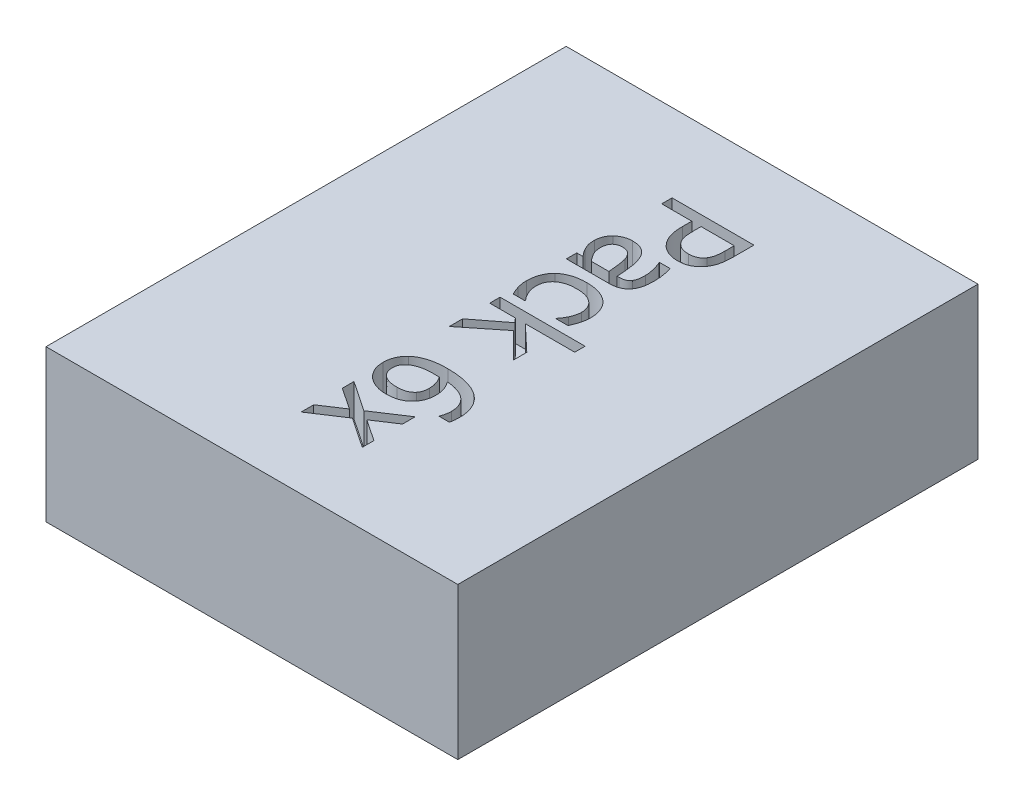
from build123d import *

# Parameters (mm, degrees)
SKETCH1_W           = 38
SKETCH1_H           = 14
BOSS_EXTRUDE1_DEPTH = 48
CUT_EXTRUDE1_DEPTH  = 3


with BuildPart() as part:
    # Sketch1 → Boss-Extrude1 (new body)
    with BuildSketch(Plane.XY):
        Rectangle(SKETCH1_W, SKETCH1_H)
    extrude(amount=BOSS_EXTRUDE1_DEPTH)

    # Sketch2 → Cut-Extrude1 (cut)
    with BuildSketch(Plane(origin=(0, 7, 0), x_dir=(1, 0, 0), z_dir=(0, 1, 0))):
        with BuildLine():
            add(Edge.make_bspline(
                [(3.247819021, -12.001203397), (3.166017395, -11.999505775), (3.003662304, -11.996136435), (2.764297073, -11.959652494), (2.531343241, -11.905343398), (2.307750042, -11.826775929), (2.094742675, -11.731458665), (1.898188136, -11.614545571), (1.715028941, -11.484211033), (1.607405271, -11.381596731), (1.553765815, -11.330453935)],
                knots=[0, 0, 0, 0, 0.000245218, 0.000486695, 0.000724751, 0.000961915, 0.001196573, 0.001423573, 0.00164708, 0.001869161, 0.001869161, 0.001869161, 0.001869161], degree=3))
            add(Edge.make_bspline(
                [(1.553765815, -11.330453935), (1.490690236, -11.263236352), (1.364664717, -11.128935074), (1.208368294, -10.900417457), (1.070026889, -10.658608827), (0.956698106, -10.395418802), (0.869496109, -10.104784869), (0.807935038, -9.782006196), (0.770776554, -9.42414577), (0.766980665, -9.173892861), (0.765000301, -9.04333272)],
                knots=[0, 0, 0, 0, 0.000276157, 0.000551763, 0.000828037, 0.00111109, 0.001409285, 0.001736539, 0.002095523, 0.0024871, 0.0024871, 0.0024871, 0.0024871], degree=3))
            Line((0.765000301, -9.04333272), (0.765000301, -8.176885755))
            Line((0.765000301, -8.176885755), (-2.007629989, -8.176885755))
            Line((-2.007629989, -8.176885755), (-2.007629989, -7.220806344))
            Line((-2.007629989, -7.220806344), (5.545397354, -7.220806344))
            Line((5.545397354, -7.220806344), (5.545397354, -9.122508047))
            add(Edge.make_bspline(
                [(5.545397354, -9.122508047), (5.543922544, -9.230596056), (5.541085497, -9.438521622), (5.520745917, -9.737857764), (5.484996583, -10.012211973), (5.436338134, -10.263551645), (5.371869763, -10.4957725), (5.28927761, -10.711729631), (5.190167504, -10.914523817), (5.108984036, -11.038908552), (5.068851523, -11.100397327)],
                knots=[0, 0, 0, 0, 0.000324257, 0.000623763, 0.000899483, 0.001153784, 0.001391202, 0.001621476, 0.001846621, 0.002066728, 0.002066728, 0.002066728, 0.002066728], degree=3))
            add(Edge.make_bspline(
                [(5.068851523, -11.100397327), (5.018725731, -11.168500818), (4.919494112, -11.303322021), (4.741782651, -11.480824552), (4.545099061, -11.634761619), (4.33037673, -11.768187733), (4.093134351, -11.87411868), (3.832096463, -11.94795925), (3.547686736, -11.993455227), (3.350079722, -11.998561121), (3.247819021, -12.001203397)],
                knots=[0, 0, 0, 0, 0.000253396, 0.000501635, 0.000750579, 0.001001412, 0.001258206, 0.001527224, 0.001813101, 0.002119709, 0.002119709, 0.002119709, 0.002119709], degree=3))
        make_face()
        with BuildLine():
            add(Edge.make_bspline(
                [(3.223917036, -10.949516045), (3.288234658, -10.947762396), (3.412914767, -10.944362936), (3.593401558, -10.91911716), (3.760270828, -10.875733826), (3.914536132, -10.815704042), (4.056140104, -10.738447022), (4.182183333, -10.640530147), (4.29865251, -10.528938843), (4.360661088, -10.440278397), (4.392126565, -10.395288762)],
                knots=[0, 0, 0, 0, 0.000192918, 0.000373973, 0.000545359, 0.000709032, 0.00086951, 0.001027268, 0.001186777, 0.001351103, 0.001351103, 0.001351103, 0.001351103], degree=3))
            add(Edge.make_bspline(
                [(4.392126565, -10.395288762), (4.418174298, -10.354073576), (4.471060507, -10.270392013), (4.529750909, -10.131861513), (4.582469222, -9.985767795), (4.620244151, -9.82673694), (4.650434169, -9.653165097), (4.670764223, -9.461036231), (4.682178311, -9.24962905), (4.683986018, -9.102106481), (4.684925885, -9.025406231)],
                knots=[0, 0, 0, 0, 0.000146033, 0.0002965, 0.00045005, 0.000611644, 0.000786018, 0.000978374, 0.001190841, 0.001420941, 0.001420941, 0.001420941, 0.001420941], degree=3))
            Line((4.684925885, -9.025406231), (4.684925885, -8.176885755))
            Line((4.684925885, -8.176885755), (1.625471771, -8.176885755))
            Line((1.625471771, -8.176885755), (1.625471771, -8.874524949))
            add(Edge.make_bspline(
                [(1.625471771, -8.874524949), (1.626346609, -8.973158383), (1.628009853, -9.160680306), (1.647617026, -9.427003126), (1.678102295, -9.663635985), (1.720536308, -9.873641097), (1.780087162, -10.060852664), (1.860877965, -10.229355242), (1.959716739, -10.382815713), (2.041895714, -10.471082164), (2.082597239, -10.514798688)],
                knots=[0, 0, 0, 0, 0.000295847, 0.000562465, 0.000800573, 0.00101123, 0.001204449, 0.001388202, 0.001570509, 0.001749407, 0.001749407, 0.001749407, 0.001749407], degree=3))
            add(Edge.make_bspline(
                [(2.082597239, -10.514798688), (2.121123908, -10.551129631), (2.196798579, -10.622491424), (2.322642342, -10.711343495), (2.450584854, -10.788752122), (2.585943778, -10.849641585), (2.730138763, -10.894186189), (2.88455006, -10.927137172), (3.05062549, -10.946611097), (3.165105632, -10.948530169), (3.223917036, -10.949516045)],
                knots=[0, 0, 0, 0, 0.000158674, 0.000311671, 0.000461036, 0.000606801, 0.000755628, 0.000912967, 0.001079921, 0.001256299, 0.001256299, 0.001256299, 0.001256299], degree=3))
        make_face(mode=Mode.SUBTRACT)
        with BuildLine():
            add(Edge.make_bspline(
                [(-1.441451713, -16.016736921), (-1.457424795, -15.995851723), (-1.491972199, -15.950680138), (-1.546770282, -15.877237547), (-1.611071154, -15.795090461), (-1.707533725, -15.677384419), (-1.819666444, -15.524797571), (-1.8923424, -15.393561549), (-1.926960789, -15.331048719)],
                knots=[0, 0, 0, 0, 7.8879e-05, 0.000170603, 0.000274897, 0.000391782, 0.000627265, 0.000841468, 0.000841468, 0.000841468, 0.000841468], degree=3))
            add(Edge.make_bspline(
                [(-1.926960789, -15.331048719), (-1.96668949, -15.249517445), (-2.043551674, -15.091780807), (-2.120256143, -14.885527112), (-2.164470294, -14.710076371), (-2.182571356, -14.556613778), (-2.197005924, -14.380224534), (-2.198206, -14.255002519), (-2.198845871, -14.188235049)],
                knots=[0, 0, 0, 0, 0.000272008, 0.000526248, 0.000658496, 0.00081378, 0.000989079, 0.001189309, 0.001189309, 0.001189309, 0.001189309], degree=3))
            add(Edge.make_bspline(
                [(-2.198845871, -14.188235049), (-2.196882187, -14.130898804), (-2.192989252, -14.017231736), (-2.169150981, -13.848782749), (-2.126789357, -13.685237961), (-2.068217129, -13.526857601), (-1.995728061, -13.374949412), (-1.908036094, -13.232289354), (-1.808586593, -13.098143203), (-1.731190509, -13.01822722), (-1.692422559, -12.978197045)],
                knots=[0, 0, 0, 0, 0.000172029, 0.000341042, 0.000509161, 0.000677889, 0.000846935, 0.001013212, 0.001179629, 0.00134665, 0.00134665, 0.00134665, 0.00134665], degree=3))
            add(Edge.make_bspline(
                [(-1.692422559, -12.978197045), (-1.65125364, -12.941539691), (-1.568167503, -12.867558689), (-1.429324361, -12.769834521), (-1.27635256, -12.684866063), (-1.11110933, -12.612586406), (-0.937220773, -12.551966014), (-0.756225836, -12.511230911), (-0.570819051, -12.484469488), (-0.445629909, -12.480998914), (-0.382294991, -12.479243102)],
                knots=[0, 0, 0, 0, 0.000165274, 0.000333552, 0.000508105, 0.000689364, 0.000874079, 0.001059614, 0.001245108, 0.001435041, 0.001435041, 0.001435041, 0.001435041], degree=3))
            add(Edge.make_bspline(
                [(-0.382294991, -12.479243102), (-0.286987744, -12.481820959), (-0.10213739, -12.486820765), (0.163779871, -12.533566762), (0.40801991, -12.611311031), (0.63000501, -12.721721927), (0.833224963, -12.863133933), (1.009552455, -13.044956932), (1.168381083, -13.258992831), (1.249049466, -13.422378107), (1.290843977, -13.507028469)],
                knots=[0, 0, 0, 0, 0.000285721, 0.000554161, 0.000806909, 0.001052095, 0.001295395, 0.001545747, 0.001808686, 0.00209138, 0.00209138, 0.00209138, 0.00209138], degree=3))
            add(Edge.make_bspline(
                [(1.290843977, -13.507028469), (1.326132356, -13.58914532), (1.398562486, -13.75769186), (1.482374065, -14.027999544), (1.549636371, -14.319183154), (1.598163266, -14.630595832), (1.637464118, -14.958680566), (1.671763242, -15.300358567), (1.700334937, -15.654469531), (1.714091732, -15.894705358), (1.721079712, -16.016736921)],
                knots=[0, 0, 0, 0, 0.000267983, 0.00055004, 0.000847546, 0.001163871, 0.001494989, 0.001838807, 0.002193991, 0.002560675, 0.002560675, 0.002560675, 0.002560675], degree=3))
            Line((1.721079712, -16.016736921), (1.904826224, -16.016736921))
            add(Edge.make_bspline(
                [(1.904826224, -16.016736921), (1.958682079, -16.015897713), (2.060813641, -16.014306248), (2.205880092, -15.994220451), (2.335011277, -15.963908315), (2.44907108, -15.920127409), (2.548850155, -15.86482269), (2.634449303, -15.7974387), (2.711344345, -15.723559287), (2.750346816, -15.664983629), (2.769779316, -15.635799031)],
                knots=[0, 0, 0, 0, 0.000161449, 0.00030617, 0.000438418, 0.000558542, 0.000671574, 0.000779144, 0.000884777, 0.000989667, 0.000989667, 0.000989667, 0.000989667], degree=3))
            add(Edge.make_bspline(
                [(2.769779316, -15.635799031), (2.788486, -15.604839727), (2.827064035, -15.540993611), (2.870822358, -15.435352306), (2.903987776, -15.319437768), (2.934155276, -15.15130751), (2.959540905, -14.93044839), (2.96249142, -14.751008581), (2.963982946, -14.660299258)],
                knots=[0, 0, 0, 0, 0.000108396, 0.000223541, 0.000341736, 0.000469478, 0.000735576, 0.001007609, 0.001007609, 0.001007609, 0.001007609], degree=3))
            add(Edge.make_bspline(
                [(2.963982946, -14.660299258), (2.962710327, -14.603494173), (2.960058949, -14.485146274), (2.941233847, -14.300518524), (2.909098284, -14.101781507), (2.850834842, -13.815739472), (2.753132051, -13.44592558), (2.639306518, -13.158431371), (2.581551182, -13.012556148)],
                knots=[0, 0, 0, 0, 0.000170406, 0.000355025, 0.000556172, 0.000774145, 0.001230755, 0.001701088, 0.001701088, 0.001701088, 0.001701088], degree=3))
            Line((2.581551182, -13.012556148), (2.581551182, -12.957282808))
            Line((2.581551182, -12.957282808), (3.563026451, -12.957282808))
            add(Edge.make_bspline(
                [(3.563026451, -12.957282808), (3.576206078, -13.005523929), (3.605046727, -13.111088781), (3.646565168, -13.284405914), (3.689436514, -13.486218598), (3.733698946, -13.711078434), (3.77362351, -13.949481382), (3.804440574, -14.192049394), (3.820403866, -14.433508801), (3.823110733, -14.594051249), (3.824454415, -14.673744124)],
                knots=[0, 0, 0, 0, 0.000150021, 0.000328287, 0.000534561, 0.000768942, 0.001015761, 0.001259606, 0.001502171, 0.001741266, 0.001741266, 0.001741266, 0.001741266], degree=3))
            add(Edge.make_bspline(
                [(3.824454415, -14.673744124), (3.823190404, -14.766379215), (3.820762184, -14.944335122), (3.805690684, -15.199871862), (3.775028282, -15.432642427), (3.735871997, -15.645826397), (3.680743874, -15.842975358), (3.605728257, -16.026970619), (3.51656203, -16.203056793), (3.439959915, -16.309923221), (3.401688051, -16.363315708)],
                knots=[0, 0, 0, 0, 0.000277925, 0.000533905, 0.000767375, 0.000981839, 0.001183755, 0.001380158, 0.00157727, 0.001774082, 0.001774082, 0.001774082, 0.001774082], degree=3))
            add(Edge.make_bspline(
                [(3.401688051, -16.363315708), (3.361142679, -16.412324931), (3.280051936, -16.510343378), (3.135205964, -16.635775228), (2.973321945, -16.741583191), (2.793824889, -16.826997021), (2.595502203, -16.892662341), (2.37777218, -16.940066388), (2.139122708, -16.968507132), (1.973128111, -16.97134313), (1.886899735, -16.972816332)],
                knots=[0, 0, 0, 0, 0.000190561, 0.000381122, 0.000572134, 0.000769246, 0.000975687, 0.001197511, 0.001436727, 0.001695323, 0.001695323, 0.001695323, 0.001695323], degree=3))
            Line((1.886899735, -16.972816332), (-2.007629989, -16.972816332))
            Line((-2.007629989, -16.972816332), (-2.007629989, -16.016736921))
            Line((-2.007629989, -16.016736921), (-1.441451713, -16.016736921))
        make_face()
        with BuildLine():
            Line((-0.655673948, -16.016736921), (0.956216184, -16.016736921))
            add(Edge.make_bspline(
                [(0.956216184, -16.016736921), (0.950957813, -15.955964744), (0.939830484, -15.827363682), (0.91746737, -15.623440767), (0.89645224, -15.397123394), (0.869720185, -15.156138813), (0.842103424, -14.915723862), (0.808391693, -14.692301147), (0.769118156, -14.493513085), (0.734842069, -14.371307301), (0.718690205, -14.313720471)],
                knots=[0, 0, 0, 0, 0.000182992, 0.000387232, 0.000615404, 0.000864841, 0.001114617, 0.001341317, 0.001542592, 0.001721962, 0.001721962, 0.001721962, 0.001721962], degree=3))
            add(Edge.make_bspline(
                [(0.718690205, -14.313720471), (0.697688107, -14.252415467), (0.656605887, -14.132496703), (0.572491778, -13.96557042), (0.470584256, -13.816785222), (0.357077393, -13.681331174), (0.219845868, -13.56946), (0.056205907, -13.491048186), (-0.130483758, -13.441941861), (-0.263452511, -13.437595647), (-0.332997147, -13.435322513)],
                knots=[0, 0, 0, 0, 0.000194255, 0.000379983, 0.000558562, 0.00073437, 0.000908648, 0.001085027, 0.00127489, 0.001483075, 0.001483075, 0.001483075, 0.001483075], degree=3))
            add(Edge.make_bspline(
                [(-0.332997147, -13.435322513), (-0.373351338, -13.43629552), (-0.45125674, -13.43817395), (-0.564969711, -13.449448034), (-0.670253823, -13.472252879), (-0.769052149, -13.501986966), (-0.859593419, -13.540743291), (-0.94370277, -13.587051689), (-1.018000468, -13.644624734), (-1.108926706, -13.730691437), (-1.203751371, -13.862918048), (-1.282223106, -14.052418779), (-1.330094258, -14.272545181), (-1.335511831, -14.429482305), (-1.338374402, -14.512405724)],
                knots=[0, 0, 0, 0, 0.000121087, 0.000233763, 0.000342169, 0.000443764, 0.000542822, 0.000637138, 0.000730955, 0.000823936, 0.001012188, 0.001213639, 0.001435463, 0.00168399, 0.00168399, 0.00168399, 0.00168399], degree=3))
            add(Edge.make_bspline(
                [(-1.338374402, -14.512405724), (-1.336368286, -14.586291243), (-1.332437283, -14.731070576), (-1.292839141, -14.942499699), (-1.233124579, -15.144082166), (-1.143467473, -15.332952126), (-1.038651645, -15.513093683), (-0.920881088, -15.686638562), (-0.79473245, -15.856013894), (-0.702161032, -15.963007413), (-0.655673948, -16.016736921)],
                knots=[0, 0, 0, 0, 0.000221416, 0.000433867, 0.000643207, 0.000850419, 0.001059247, 0.001268069, 0.001479303, 0.001692383, 0.001692383, 0.001692383, 0.001692383], degree=3))
        make_face(mode=Mode.SUBTRACT)
        with BuildLine():
            add(Edge.make_bspline(
                [(-2.10323793, -20.562595744), (-2.100764893, -20.467399402), (-2.095920274, -20.280912134), (-2.063051128, -20.006718322), (-2.005887403, -19.745479998), (-1.928755061, -19.495787361), (-1.827824028, -19.260606451), (-1.700623466, -19.043059201), (-1.553533674, -18.839998159), (-1.436111287, -18.721715544), (-1.377215128, -18.662387916)],
                knots=[0, 0, 0, 0, 0.00028558, 0.000559444, 0.000826965, 0.00108683, 0.001342422, 0.001592756, 0.001841642, 0.002092101, 0.002092101, 0.002092101, 0.002092101], degree=3))
            add(Edge.make_bspline(
                [(-1.377215128, -18.662387916), (-1.313673882, -18.6061265), (-1.184521663, -18.491771069), (-0.964883671, -18.345382187), (-0.720155845, -18.222116461), (-0.453824254, -18.115055659), (-0.161866683, -18.032109891), (0.153859849, -17.970971941), (0.494288656, -17.935330072), (0.729062281, -17.931085143), (0.850151124, -17.928895743)],
                knots=[0, 0, 0, 0, 0.000254398, 0.000517082, 0.000789004, 0.001075286, 0.00137693, 0.001698033, 0.002039033, 0.002402241, 0.002402241, 0.002402241, 0.002402241], degree=3))
            add(Edge.make_bspline(
                [(0.850151124, -17.928895743), (0.97026461, -17.930925912), (1.203145224, -17.934862082), (1.539509153, -17.972559569), (1.851006206, -18.033958002), (2.136160005, -18.123708073), (2.398887118, -18.230715281), (2.638762239, -18.357323036), (2.859119234, -18.497758538), (2.989502734, -18.608120381), (3.053615391, -18.662387916)],
                knots=[0, 0, 0, 0, 0.000360222, 0.000698412, 0.001013945, 0.001311151, 0.001593841, 0.001863798, 0.002124011, 0.00237575, 0.00237575, 0.00237575, 0.00237575], degree=3))
            add(Edge.make_bspline(
                [(3.053615391, -18.662387916), (3.113455645, -18.719692119), (3.233873841, -18.83500695), (3.38671586, -19.035792313), (3.519400798, -19.255717154), (3.628873286, -19.494612855), (3.716738304, -19.747187769), (3.779711905, -20.010856037), (3.818095574, -20.283593967), (3.822317918, -20.468854347), (3.824454415, -20.562595744)],
                knots=[0, 0, 0, 0, 0.000248239, 0.000499539, 0.0007542, 0.001017546, 0.001286364, 0.001555216, 0.001829654, 0.002110756, 0.002110756, 0.002110756, 0.002110756], degree=3))
            add(Edge.make_bspline(
                [(3.824454415, -20.562595744), (3.823358165, -20.639866696), (3.821187765, -20.792850689), (3.793478004, -21.019749285), (3.754918591, -21.242960972), (3.69502676, -21.459605192), (3.626960944, -21.668031936), (3.552662946, -21.866436064), (3.477048469, -22.054517271), (3.418355671, -22.173323275), (3.389737058, -22.23125309)],
                knots=[0, 0, 0, 0, 0.000231671, 0.000458671, 0.000684883, 0.000910636, 0.001132198, 0.001342538, 0.001546165, 0.001739938, 0.001739938, 0.001739938, 0.001739938], degree=3))
            Line((3.389737058, -22.23125309), (2.294727358, -22.23125309))
            Line((2.294727358, -22.23125309), (2.294727358, -22.174485875))
            add(Edge.make_bspline(
                [(2.294727358, -22.174485875), (2.325433744, -22.135896876), (2.393054021, -22.050917848), (2.496617453, -21.904752431), (2.608637808, -21.726938217), (2.677728577, -21.592973214), (2.714505975, -21.521662903)],
                knots=[0, 0, 0, 0, 0.000147924, 0.000325751, 0.000537149, 0.000777751, 0.000777751, 0.000777751, 0.000777751], degree=3))
            add(Edge.make_bspline(
                [(2.714505975, -21.521662903), (2.747439044, -21.450057351), (2.817330328, -21.298094472), (2.892588593, -21.051223165), (2.953719106, -20.793462128), (2.960637491, -20.617706611), (2.963982946, -20.532718262)],
                knots=[0, 0, 0, 0, 0.000236174, 0.000501213, 0.000773115, 0.001027705, 0.001027705, 0.001027705, 0.001027705], degree=3))
            add(Edge.make_bspline(
                [(2.963982946, -20.532718262), (2.962223067, -20.471880724), (2.958788282, -20.353143104), (2.9329873, -20.179209049), (2.889605441, -20.015038085), (2.830196515, -19.858725809), (2.749371656, -19.714240653), (2.655727314, -19.576482685), (2.541416031, -19.450426109), (2.412178976, -19.332927457), (2.267103893, -19.226143874), (2.106002834, -19.135493093), (1.931540606, -19.057322907), (1.743025739, -18.993311949), (1.54005877, -18.943942062), (1.322616258, -18.91054993), (1.091086352, -18.889279264), (0.931864839, -18.886434902), (0.850151124, -18.884975153)],
                knots=[0, 0, 0, 0, 0.000182473, 0.000356135, 0.000526076, 0.000691141, 0.000856266, 0.001021608, 0.001189833, 0.001365387, 0.001544963, 0.001728958, 0.001918862, 0.00211775, 0.002325361, 0.002544681, 0.002777174, 0.003022283, 0.003022283, 0.003022283, 0.003022283], degree=3))
            add(Edge.make_bspline(
                [(0.850151124, -18.884975153), (0.769950288, -18.886632652), (0.61379209, -18.88985995), (0.386501372, -18.908375216), (0.172957577, -18.943295745), (-0.027138069, -18.99013367), (-0.213836604, -19.052168751), (-0.387948434, -19.12558205), (-0.546484624, -19.216669989), (-0.692774525, -19.31716497), (-0.820613156, -19.43309913), (-0.934627509, -19.557699689), (-1.030489691, -19.694230076), (-1.108895199, -19.84172417), (-1.168460844, -20.000095197), (-1.212101395, -20.168249038), (-1.237507781, -20.347203978), (-1.24098564, -20.469894954), (-1.242766461, -20.532718262)],
                knots=[0, 0, 0, 0, 0.00024063, 0.000468528, 0.000683422, 0.00088923, 0.001084334, 0.001273036, 0.001454994, 0.00163196, 0.001804404, 0.001971517, 0.002137714, 0.002303446, 0.0024713, 0.002644131, 0.002823707, 0.003012148, 0.003012148, 0.003012148, 0.003012148], degree=3))
            add(Edge.make_bspline(
                [(-1.242766461, -20.532718262), (-1.24039115, -20.610028514), (-1.235678248, -20.763421318), (-1.200187408, -20.990810352), (-1.142141105, -21.212772845), (-1.059504511, -21.426736592), (-0.958561349, -21.631024822), (-0.84596111, -21.825900271), (-0.716974056, -22.007199678), (-0.621173881, -22.118908109), (-0.573510873, -22.174485875)],
                knots=[0, 0, 0, 0, 0.000231859, 0.000460035, 0.000688676, 0.000918951, 0.001146775, 0.001371731, 0.001593495, 0.001813074, 0.001813074, 0.001813074, 0.001813074], degree=3))
            Line((-0.573510873, -22.174485875), (-0.573510873, -22.23125309))
            Line((-0.573510873, -22.23125309), (-1.659557329, -22.23125309))
            add(Edge.make_bspline(
                [(-1.659557329, -22.23125309), (-1.684022806, -22.177997952), (-1.738081447, -22.060326004), (-1.820870271, -21.876255851), (-1.900728133, -21.685037996), (-1.938956724, -21.554390215), (-1.956838271, -21.493279295)],
                knots=[0, 0, 0, 0, 0.000175808, 0.000388464, 0.000605672, 0.000796561, 0.000796561, 0.000796561, 0.000796561], degree=3))
            add(Edge.make_bspline(
                [(-1.956838271, -21.493279295), (-1.978310622, -21.416752401), (-2.018677821, -21.272884761), (-2.061148588, -21.093445873), (-2.084027486, -20.950923289), (-2.09581839, -20.833730497), (-2.100890129, -20.702564472), (-2.102427691, -20.610899734), (-2.10323793, -20.562595744)],
                knots=[0, 0, 0, 0, 0.000238459, 0.000448294, 0.000552673, 0.000671292, 0.000801397, 0.000946333, 0.000946333, 0.000946333, 0.000946333], degree=3))
        make_face()
        Polygon((-2.007629989, -27.776513672), (-2.007629989, -26.551536927), (0.726159575, -24.442186727), (0.351197182, -24.047803971), (-2.007629989, -24.047803971), (-2.007629989, -23.09172456), (5.832221178, -23.09172456), (5.832221178, -24.047803971), (1.277399111, -24.047803971), (3.633238533, -26.269194726), (3.633238533, -27.489689849), (1.274411362, -25.153270789), align=None)
        with BuildLine():
            add(Edge.make_bspline(
                [(0.452780619, -36.094404544), (0.355557088, -36.092238529), (0.164907046, -36.087991092), (-0.115519139, -36.050626268), (-0.384377161, -35.991983101), (-0.640080953, -35.907630687), (-0.879391958, -35.804442255), (-1.098456449, -35.681861697), (-1.300303549, -35.547512162), (-1.417771478, -35.440617388), (-1.475810817, -35.387802105)],
                knots=[0, 0, 0, 0, 0.00029155, 0.000571715, 0.000847171, 0.001115973, 0.001378236, 0.00162766, 0.001868401, 0.002103514, 0.002103514, 0.002103514, 0.002103514], degree=3))
            add(Edge.make_bspline(
                [(-1.475810817, -35.387802105), (-1.532845285, -35.33118844), (-1.645784275, -35.219082719), (-1.790983184, -35.033101872), (-1.917027799, -34.83863168), (-2.020749743, -34.633672813), (-2.099988392, -34.416870307), (-2.156832708, -34.189585475), (-2.191859397, -33.951779582), (-2.19649552, -33.789475975), (-2.198845871, -33.707193766)],
                knots=[0, 0, 0, 0, 0.00024088, 0.000476988, 0.00070614, 0.000935293, 0.001164519, 0.001397127, 0.001637125, 0.001883904, 0.001883904, 0.001883904, 0.001883904], degree=3))
            add(Edge.make_bspline(
                [(-2.198845871, -33.707193766), (-2.197073289, -33.623914354), (-2.193598454, -33.460659793), (-2.159370797, -33.222108145), (-2.106329994, -32.995094009), (-2.029981289, -32.779914996), (-1.929732166, -32.577720404), (-1.812836678, -32.385171794), (-1.670404927, -32.207305082), (-1.56206304, -32.100239926), (-1.507182173, -32.04600579)],
                knots=[0, 0, 0, 0, 0.000249696, 0.000489485, 0.000721382, 0.000948185, 0.00117267, 0.001397372, 0.001622744, 0.001854102, 0.001854102, 0.001854102, 0.001854102], degree=3))
            add(Edge.make_bspline(
                [(-1.507182173, -32.04600579), (-1.433503275, -31.98275666), (-1.282148432, -31.852827163), (-1.018616304, -31.69114926), (-0.721452857, -31.551231658), (-0.45081207, -31.451229732), (-0.215972503, -31.385353908), (-0.027084499, -31.340607513), (0.171496199, -31.300977698), (0.380680754, -31.272419201), (0.599347123, -31.248294639), (0.827991922, -31.230302792), (1.067158154, -31.219719347), (1.230082224, -31.218845588), (1.313252088, -31.21839955)],
                knots=[0, 0, 0, 0, 0.000290941, 0.000597666, 0.000923745, 0.001275368, 0.001461689, 0.001655179, 0.001857625, 0.002068891, 0.002288302, 0.002517567, 0.002756815, 0.00300631, 0.00300631, 0.00300631, 0.00300631], degree=3))
            add(Edge.make_bspline(
                [(1.313252088, -31.21839955), (1.475181099, -31.220266056), (1.791068155, -31.22390719), (2.252836527, -31.264699503), (2.690710435, -31.325626197), (3.104565884, -31.413983234), (3.493850695, -31.526250435), (3.857517429, -31.667116577), (4.195818313, -31.834973533), (4.40328417, -31.970275811), (4.505660995, -32.037042545)],
                knots=[0, 0, 0, 0, 0.000485656, 0.000947406, 0.001389585, 0.00181121, 0.00221587, 0.002603703, 0.002979833, 0.003346255, 0.003346255, 0.003346255, 0.003346255], degree=3))
            add(Edge.make_bspline(
                [(4.505660995, -32.037042545), (4.598660928, -32.107528177), (4.784082039, -32.248060794), (5.028496991, -32.498298178), (5.238688653, -32.779656922), (5.388148966, -33.034896915), (5.48891317, -33.252310108), (5.554978725, -33.422543798), (5.611972648, -33.59895134), (5.658275509, -33.782019698), (5.692201296, -33.971866592), (5.717179981, -34.167307812), (5.734936092, -34.369154006), (5.736049341, -34.505879153), (5.736613237, -34.575134606)],
                knots=[0, 0, 0, 0, 0.000349723, 0.000697269, 0.001045044, 0.001401188, 0.001582317, 0.00176347, 0.001948662, 0.002138155, 0.002329493, 0.002526832, 0.002729173, 0.00293687, 0.00293687, 0.00293687, 0.00293687], degree=3))
            add(Edge.make_bspline(
                [(5.736613237, -34.575134606), (5.7357596, -34.656365076), (5.734112484, -34.813101488), (5.713471489, -35.037379144), (5.686250395, -35.241466149), (5.649434749, -35.366214494), (5.632042051, -35.425148957)],
                knots=[0, 0, 0, 0, 0.000243575, 0.000469984, 0.000675559, 0.000859645, 0.000859645, 0.000859645, 0.000859645], degree=3))
            Line((5.632042051, -35.425148957), (4.684925885, -35.425148957))
            Line((4.684925885, -35.425148957), (4.684925885, -35.380332734))
            add(Edge.make_bspline(
                [(4.684925885, -35.380332734), (4.697438132, -35.35567427), (4.724367716, -35.302602895), (4.755104232, -35.211986143), (4.789471658, -35.108588368), (4.828091271, -34.94751903), (4.868804361, -34.727862475), (4.873652929, -34.545993045), (4.876141767, -34.452636931)],
                knots=[0, 0, 0, 0, 8.2853e-05, 0.000178321, 0.00028651, 0.000409698, 0.00067494, 0.000954694, 0.000954694, 0.000954694, 0.000954694], degree=3))
            add(Edge.make_bspline(
                [(4.876141767, -34.452636931), (4.874123903, -34.377341798), (4.870178551, -34.230123893), (4.839628336, -34.01542613), (4.79038346, -33.811515333), (4.720517729, -33.618177177), (4.628315821, -33.437053638), (4.518644871, -33.266047764), (4.387364629, -33.107113058), (4.236487154, -32.958944327), (4.064989279, -32.824903391), (3.876147583, -32.701992438), (3.664695172, -32.599207339), (3.436443038, -32.505176556), (3.187229153, -32.430755191), (2.92006449, -32.367371543), (2.633035714, -32.319660961), (2.434300083, -32.300735857), (2.33207421, -32.291001139)],
                knots=[0, 0, 0, 0, 0.000225817, 0.00044152, 0.000649131, 0.000854233, 0.001056663, 0.001257632, 0.001462489, 0.001673765, 0.001890742, 0.002114509, 0.002348338, 0.002594954, 0.002854376, 0.003127588, 0.003418368, 0.003726371, 0.003726371, 0.003726371, 0.003726371], degree=3))
            add(Edge.make_bspline(
                [(2.33207421, -32.291001139), (2.373838157, -32.35015266), (2.455915376, -32.466401072), (2.561577117, -32.649072273), (2.655460037, -32.832256097), (2.731467719, -33.020441326), (2.794529461, -33.213065757), (2.837335453, -33.41433103), (2.863076223, -33.624357565), (2.866587975, -33.7673724), (2.868375005, -33.840148559)],
                knots=[0, 0, 0, 0, 0.000217121, 0.000426701, 0.00063247, 0.000834149, 0.001034935, 0.001239748, 0.001450427, 0.001668717, 0.001668717, 0.001668717, 0.001668717], degree=3))
            add(Edge.make_bspline(
                [(2.868375005, -33.840148559), (2.867158024, -33.910390642), (2.864798254, -34.046592666), (2.848647667, -34.244279128), (2.820560932, -34.428579422), (2.780010409, -34.602871512), (2.722349936, -34.772643436), (2.641758356, -34.94185165), (2.539629567, -35.115146403), (2.457145052, -35.226697059), (2.414237285, -35.284724793)],
                knots=[0, 0, 0, 0, 0.000210721, 0.000408596, 0.000594522, 0.000769535, 0.000944802, 0.001131256, 0.001330837, 0.001547217, 0.001547217, 0.001547217, 0.001547217], degree=3))
            add(Edge.make_bspline(
                [(2.414237285, -35.284724793), (2.359124337, -35.350036257), (2.249535225, -35.479904566), (2.055655006, -35.646776183), (1.840073484, -35.786370507), (1.603539446, -35.900169759), (1.346018714, -35.989298913), (1.066334783, -36.047945467), (0.766713889, -36.089123939), (0.559495826, -36.09260951), (0.452780619, -36.094404544)],
                knots=[0, 0, 0, 0, 0.000256059, 0.000509159, 0.000763986, 0.001024559, 0.001294789, 0.001579321, 0.001880609, 0.002200522, 0.002200522, 0.002200522, 0.002200522], degree=3))
        make_face()
        with BuildLine():
            add(Edge.make_bspline(
                [(0.413939893, -35.042717192), (0.489205296, -35.041480918), (0.633623549, -35.03910877), (0.840765312, -35.015715765), (1.029484338, -34.982029951), (1.199920377, -34.928896232), (1.354864296, -34.859090198), (1.497942885, -34.772653514), (1.627935187, -34.665064351), (1.703632334, -34.581586387), (1.741993949, -34.539281628)],
                knots=[0, 0, 0, 0, 0.000225699, 0.000433067, 0.00062468, 0.000799973, 0.000967127, 0.001133404, 0.001300003, 0.00147118, 0.00147118, 0.00147118, 0.00147118], degree=3))
            add(Edge.make_bspline(
                [(1.741993949, -34.539281628), (1.767767983, -34.507034974), (1.819062932, -34.442858351), (1.880081769, -34.336106441), (1.926909069, -34.223013715), (1.969660978, -34.063450112), (2.001325636, -33.855850985), (2.005701568, -33.68739139), (2.007903535, -33.60262258)],
                knots=[0, 0, 0, 0, 0.000123694, 0.000246174, 0.000367408, 0.000489915, 0.000740921, 0.000995161, 0.000995161, 0.000995161, 0.000995161], degree=3))
            add(Edge.make_bspline(
                [(2.007903535, -33.60262258), (2.007055202, -33.545279029), (2.005367424, -33.431192719), (1.982555052, -33.26210561), (1.950839116, -33.094837621), (1.901668251, -32.930602293), (1.842460817, -32.767652469), (1.769508873, -32.60696078), (1.686542587, -32.446837413), (1.622194551, -32.343377182), (1.589618793, -32.291001139)],
                knots=[0, 0, 0, 0, 0.000171899, 0.000341998, 0.000511043, 0.000682182, 0.000855632, 0.001030823, 0.001211236, 0.001396211, 0.001396211, 0.001396211, 0.001396211], degree=3))
            add(Edge.make_bspline(
                [(1.589618793, -32.291001139), (1.552785518, -32.287788577), (1.480176603, -32.281455701), (1.368065613, -32.275738525), (1.244582435, -32.270509623), (1.156901187, -32.27023707), (1.10859134, -32.270086902)],
                knots=[0, 0, 0, 0, 0.000110909, 0.000218634, 0.000336735, 0.000481649, 0.000481649, 0.000481649, 0.000481649], degree=3))
            add(Edge.make_bspline(
                [(1.10859134, -32.270086902), (0.983046482, -32.271513204), (0.744048317, -32.274228439), (0.404601078, -32.302271789), (0.103150259, -32.348562837), (-0.160873736, -32.414806016), (-0.390432304, -32.493936296), (-0.590003594, -32.58251933), (-0.761663839, -32.678469542), (-0.858231293, -32.756321111), (-0.903657045, -32.792942829)],
                knots=[0, 0, 0, 0, 0.000376563, 0.000716858, 0.001020908, 0.001290473, 0.001532361, 0.001748353, 0.001945137, 0.002119927, 0.002119927, 0.002119927, 0.002119927], degree=3))
            add(Edge.make_bspline(
                [(-0.903657045, -32.792942829), (-0.941024327, -32.828257433), (-1.013016997, -32.896295365), (-1.108967912, -33.003567049), (-1.183610696, -33.115451439), (-1.24373662, -33.228176843), (-1.284301484, -33.345227905), (-1.317324701, -33.464129371), (-1.334873864, -33.588653267), (-1.337197393, -33.673285609), (-1.338374402, -33.71615701)],
                knots=[0, 0, 0, 0, 0.000154238, 0.000297159, 0.000430575, 0.000556858, 0.000679256, 0.00080137, 0.000926651, 0.001055263, 0.001055263, 0.001055263, 0.001055263], degree=3))
            add(Edge.make_bspline(
                [(-1.338374402, -33.71615701), (-1.336734416, -33.764517087), (-1.33352561, -33.859138686), (-1.314415928, -33.997581378), (-1.280201628, -34.128668039), (-1.229717271, -34.251721497), (-1.168323761, -34.369157259), (-1.094027838, -34.480587634), (-1.002455657, -34.582246999), (-0.899709736, -34.678213127), (-0.782988081, -34.765258894), (-0.651925438, -34.839991538), (-0.507235069, -34.90318536), (-0.348639193, -34.952844396), (-0.17692405, -34.993345458), (0.00769338, -35.023340301), (0.206513419, -35.039073128), (0.343204532, -35.041474515), (0.413939893, -35.042717192)],
                knots=[0, 0, 0, 0, 0.000145098, 0.0002839, 0.000418332, 0.000550377, 0.000682016, 0.000815432, 0.000950906, 0.001091497, 0.001236702, 0.001386604, 0.001543141, 0.001709438, 0.001884451, 0.002072085, 0.00226996, 0.002482174, 0.002482174, 0.002482174, 0.002482174], degree=3))
        make_face(mode=Mode.SUBTRACT)
        Polygon((-2.007629989, -41.448449243), (-2.007629989, -40.289202958), (-0.025259086, -38.980569265), (-2.007629989, -37.645045838), (-2.007629989, -36.572444249), (0.781432916, -38.451737841), (3.633238533, -36.572444249), (3.633238533, -37.733184409), (1.649373756, -39.038830354), (3.633238533, -40.377341529), (3.633238533, -41.448449243), (0.847163376, -39.569155652), align=None)
    extrude(amount=-CUT_EXTRUDE1_DEPTH, mode=Mode.SUBTRACT)


solid = part.part
